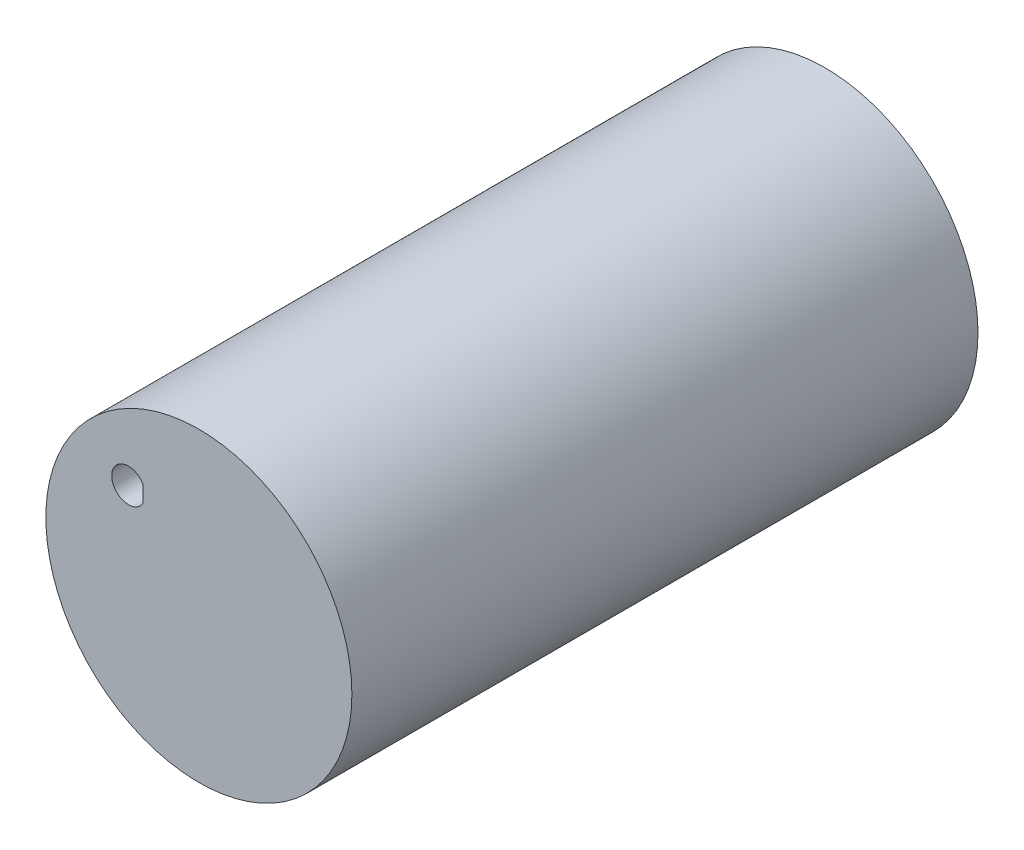
from build123d import *

# Parameters (mm, degrees)
SKETCH1_R           = 29.083
BOSS_EXTRUDE1_DEPTH = 118.999
CUT_EXTRUDE1_DEPTH  = 134.293395672


with BuildPart() as part:
    # Sketch1 → Boss-Extrude1 (new body)
    with BuildSketch(Plane.XY):
        with Locations((23.457902541, 0)):
            Circle(SKETCH1_R)
    extrude(amount=BOSS_EXTRUDE1_DEPTH)

    # Sketch2 → Cut-Extrude1 (cut, through all)
    with BuildSketch(Plane.XY.offset(118.999)):
        with BuildLine():
            Line((12.821213261, 11.550738719), (12.821213261, 14.725738719))
            ThreePointArc((12.821213261, 14.725738719), (6.896582604, 13.138238719), (12.821213261, 11.550738719))
        make_face()
    extrude(amount=-CUT_EXTRUDE1_DEPTH, mode=Mode.SUBTRACT)


solid = part.part
